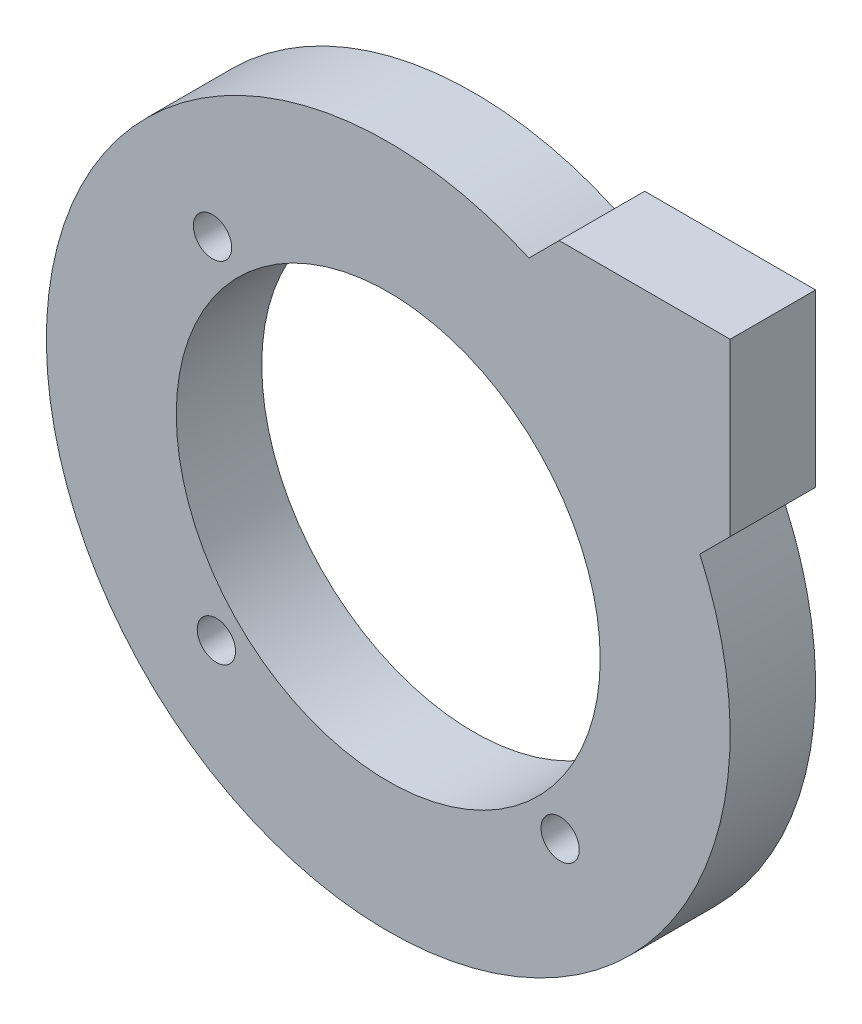
from build123d import *

# Parameters (mm, degrees)
SKETCH1_R           = 15.748
BOSS_EXTRUDE1_DEPTH = 6.35
SKETCH2_R           = 1.4224
CUT_EXTRUDE2_DEPTH  = 6.35


with BuildPart() as part:
    # Sketch1 → Boss-Extrude1 (new body)
    with BuildSketch(Plane.XY):
        with BuildLine():
            Line((23.150520825, 10.450520825), (25.4, 12.7))
            Line((25.4, 12.7), (25.4, 25.4))
            Line((25.4, 25.4), (12.7, 25.4))
            Line((12.7, 25.4), (10.450520825, 23.150520825))
            ThreePointArc((10.450520825, 23.150520825), (-17.960512242, -17.960512242), (23.150520825, 10.450520825))
        make_face()
        Circle(SKETCH1_R, mode=Mode.SUBTRACT)
    extrude(amount=BOSS_EXTRUDE1_DEPTH)

    # Sketch2 → Cut-Extrude2 (cut)
    with BuildSketch(Plane.XY.offset(6.35)):
        with Locations((12.76910233, -13.056515019)):
            Circle(SKETCH2_R)
        with Locations((-13.056515019, 12.76910233)):
            Circle(SKETCH2_R)
        with Locations((-12.76910233, -13.056515019)):
            Circle(SKETCH2_R)
    extrude(amount=-CUT_EXTRUDE2_DEPTH, mode=Mode.SUBTRACT)


solid = part.part
